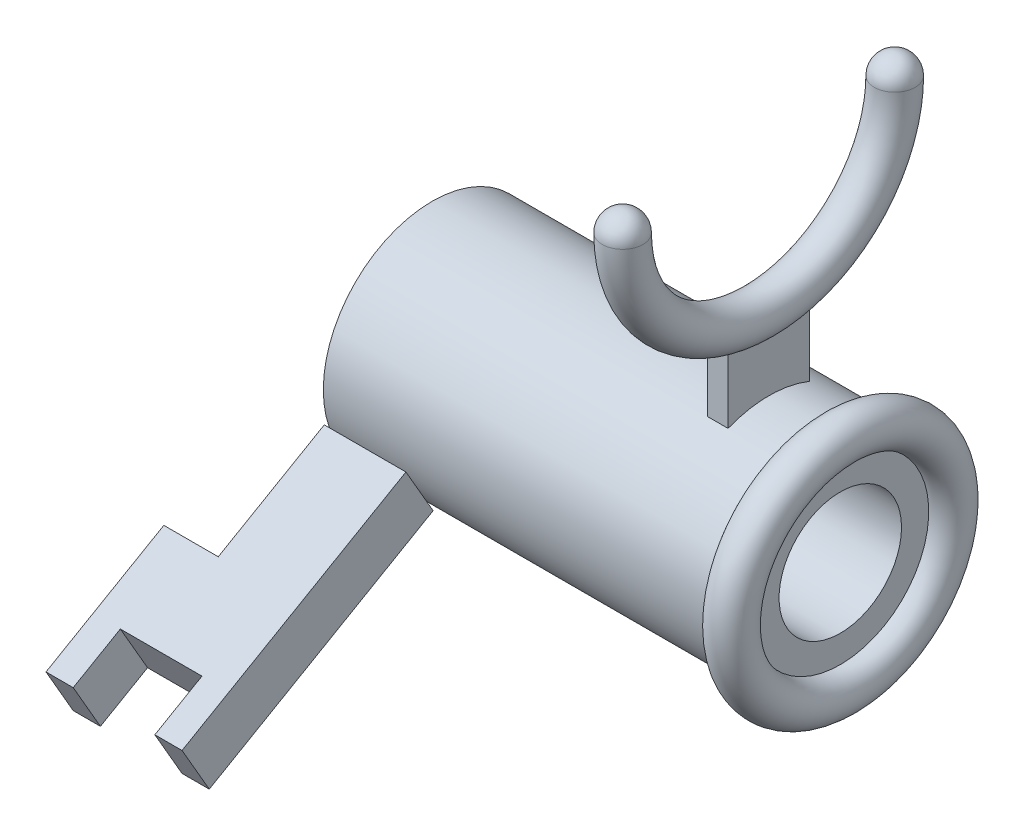
from build123d import *

# Parameters (mm, degrees)
SKETCH2_R           = 40
BOSS_EXTRUDE1_DEPTH = 150
CUT_EXTRUDE1_REACH  = 152
SKETCH3_R           = 22.5
SKETCH4_R           = 7.5
SKETCH10_R          = 7.5
REVOLVE4_ANGLE      = 180
REVOLVE_THIN1_ANGLE = 180
REVOLVE5_ANGLE      = 180
BOSS_EXTRUDE2_START = 37.080992
SKETCH14_W          = 7.5
SKETCH14_H          = 30
BOSS_EXTRUDE2_DEPTH = 23.451527
BOSS_EXTRUDE3_DEPTH = 10


with BuildPart() as part:
    # Sketch2 → Boss-Extrude1 (new body)
    with BuildSketch(Plane(origin=(0, 0, 0), x_dir=(0, 0, -1), z_dir=(1, 0, 0))):
        Circle(SKETCH2_R)
    extrude(amount=BOSS_EXTRUDE1_DEPTH)

    # Sketch3 → Cut-Extrude1 (cut, up to next)
    with BuildSketch(Plane(origin=(150, 0, 0), x_dir=(0, 0, -1), z_dir=(1, 0, 0)), mode=Mode.PRIVATE) as cut_extrude1_sk1:
        Circle(SKETCH3_R)
    cut_extrude1_tool1 = extrude(cut_extrude1_sk1.sketch, amount=-CUT_EXTRUDE1_REACH, mode=Mode.PRIVATE) & part.part
    add(cut_extrude1_tool1.solids().sort_by_distance((150, 0, 0))[0], mode=Mode.SUBTRACT)

    # Sketch4 → Revolve1 (revolve)
    with BuildSketch(Plane(origin=(0, 0, 0), x_dir=(1, 0, 0), z_dir=(0, 1, 0))):
        with Locations((150, 40)):
            Circle(SKETCH4_R)
    revolve(axis=Axis((-12.406520542, 0, 0), (1, 0, 0)))



with BuildPart() as body_2:
    # Sketch10 → Revolve4 (revolve)
    with BuildSketch(Plane(origin=(0, 115, 0), x_dir=(1, 0, 0), z_dir=(0, 1, 0))):
        with Locations((120, 50)):
            Circle(SKETCH10_R)
    revolve(axis=Axis((-32.41140005, 115, 0), (-1, 0, 0)), revolution_arc=REVOLVE4_ANGLE)

    # Sketch12 → Revolve-Thin1 (revolve)
    with BuildSketch(Plane(origin=(0, 115, 0), x_dir=(1, 0, 0), z_dir=(0, 1, 0))):
        with BuildLine():
            ThreePointArc((112.5, 50), (120, 57.5), (127.5, 50))
            Line((127.5, 50), (124.96, 50))
            ThreePointArc((124.96, 50), (120, 54.96), (115.04, 50))
            Line((115.04, 50), (112.5, 50))
        make_face()
    revolve(axis=Axis((112.5, 115, -50), (1, 0, 0)), revolution_arc=REVOLVE_THIN1_ANGLE)

    # Sketch13 → Revolve5 (revolve)
    with BuildSketch(Plane(origin=(0, 115, 0), x_dir=(1, 0, 0), z_dir=(0, 1, 0))):
        with BuildLine():
            Line((112.5, -50), (127.5, -50))
            ThreePointArc((127.5, -50), (120, -42.5), (112.5, -50))
        make_face()
    revolve(axis=Axis((112.5, 115, 50), (1, 0, 0)), revolution_arc=REVOLVE5_ANGLE)


with BuildPart() as part_1:
    add(part.part)

    add(body_2.part)  # Boss-Extrude2 merges body 2
    # Sketch14 → Boss-Extrude2 (add)
    with BuildSketch(Plane(origin=(0, 0, 0), x_dir=(1, 0, 0), z_dir=(0, 1, 0)).offset(BOSS_EXTRUDE2_START)):
        with Locations((120, 0)):
            Rectangle(SKETCH14_W, SKETCH14_H)
    extrude(amount=BOSS_EXTRUDE2_DEPTH)


with BuildPart() as body_2_2:
    # Sketch15 → Boss-Extrude3 (new body, symmetric)
    with BuildSketch(Plane(origin=(0, 0, 0), x_dir=(-1, 0, 0), z_dir=(0, 0.866025404, 0.5))):
        Polygon((0, 40), (0, 85), (20, 85), (20, 135), (10, 135), (10, 115), (-20, 115), (-20, 135), (-30, 135), (-30, 40), align=None)
    extrude(amount=BOSS_EXTRUDE3_DEPTH, both=True)


solid = Compound([part_1.part, body_2_2.part])
